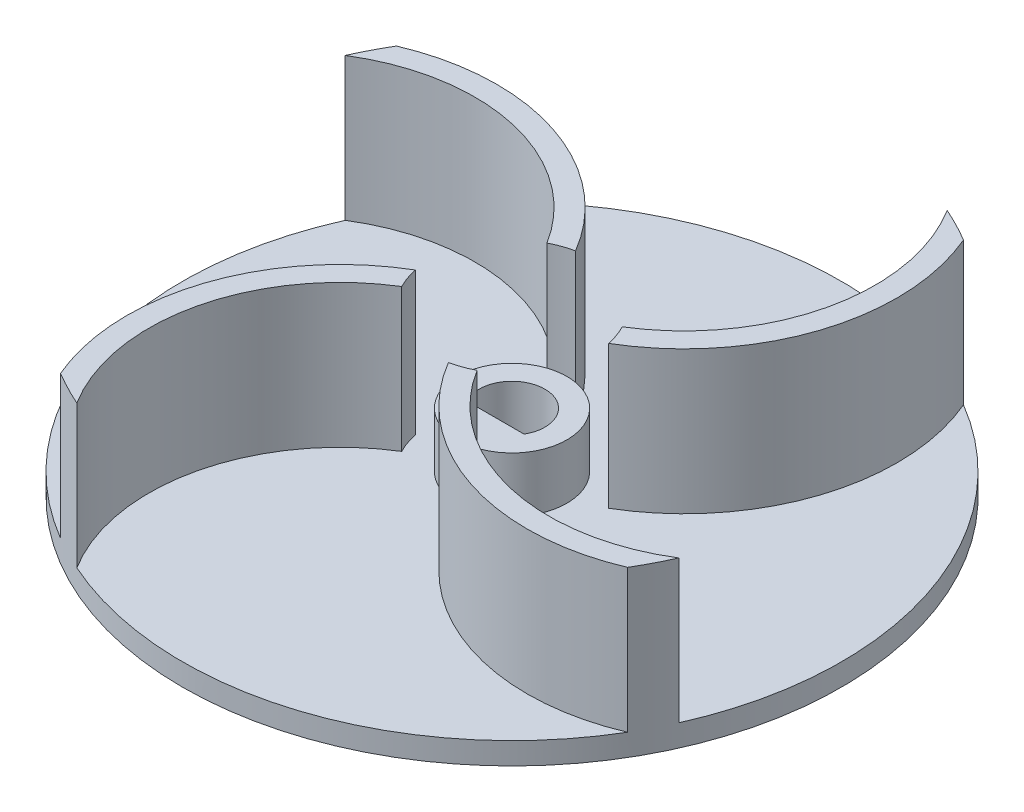
from build123d import *

# Parameters (mm, degrees)
SKETCH1_R           = 30
BOSS_EXTRUDE1_DEPTH = 2
SKETCH2_R           = 5
BOSS_EXTRUDE2_DEPTH = 7
BOSS_EXTRUDE3_DEPTH = 13
CUT_EXTRUDE1_DEPTH  = 16
CIRPATTERN2_COUNT   = 4


with BuildPart() as part:
    # Sketch1 → Boss-Extrude1 (new body)
    with BuildSketch(Plane(origin=(0, 0, 0), x_dir=(1, 0, 0), z_dir=(0, 1, 0))):
        Circle(SKETCH1_R)
    extrude(amount=BOSS_EXTRUDE1_DEPTH)

    # Sketch2 → Boss-Extrude2 (add)
    with BuildSketch(Plane(origin=(0, 0, 0), x_dir=(1, 0, 0), z_dir=(0, 1, 0))):
        Circle(SKETCH2_R)
    extrude(amount=BOSS_EXTRUDE2_DEPTH)

    # Sketch3 → Boss-Extrude3 (add)
    with BuildSketch(Plane(origin=(0, 2, 0), x_dir=(1, 0, 0), z_dir=(0, 1, 0))):
        with BuildLine():
            ThreePointArc((-1.505806951, 7.292266896), (-12.151790035, 15.86929072), (-25.810761164, 15.290670625))
            ThreePointArc((-25.810761164, 15.290670625), (-26.649690738, 13.776573724), (-27.399897799, 12.216611666))
            ThreePointArc((-27.399897799, 12.216611666), (-14.251932533, 14.383859932), (-3.429686075, 6.60922571))
            ThreePointArc((-3.429686075, 6.60922571), (-2.491266579, 7.016993793), (-1.505806951, 7.292266896))
        make_face()
    boss_extrude3 = extrude(amount=BOSS_EXTRUDE3_DEPTH)

    # Sketch4 → Cut-Extrude1 (cut, through all)
    with BuildSketch(Plane(origin=(0, 0, 0), x_dir=(1, 0, 0), z_dir=(0, 1, 0))):
        with BuildLine():
            Line((-2.598076211, -1.5), (2.598076211, -1.5))
            ThreePointArc((2.598076211, -1.5), (0, 3), (-2.598076211, -1.5))
        make_face()
    extrude(amount=CUT_EXTRUDE1_DEPTH, mode=Mode.SUBTRACT)

    # CirPattern2: Boss-Extrude3 ×4 about axis
    cirpattern2_axis = Axis((0, 0, 0), (0, 1, 0))
    for i in range(1, CIRPATTERN2_COUNT):
        add(boss_extrude3.rotate(cirpattern2_axis, i * 360 / CIRPATTERN2_COUNT))


solid = part.part
